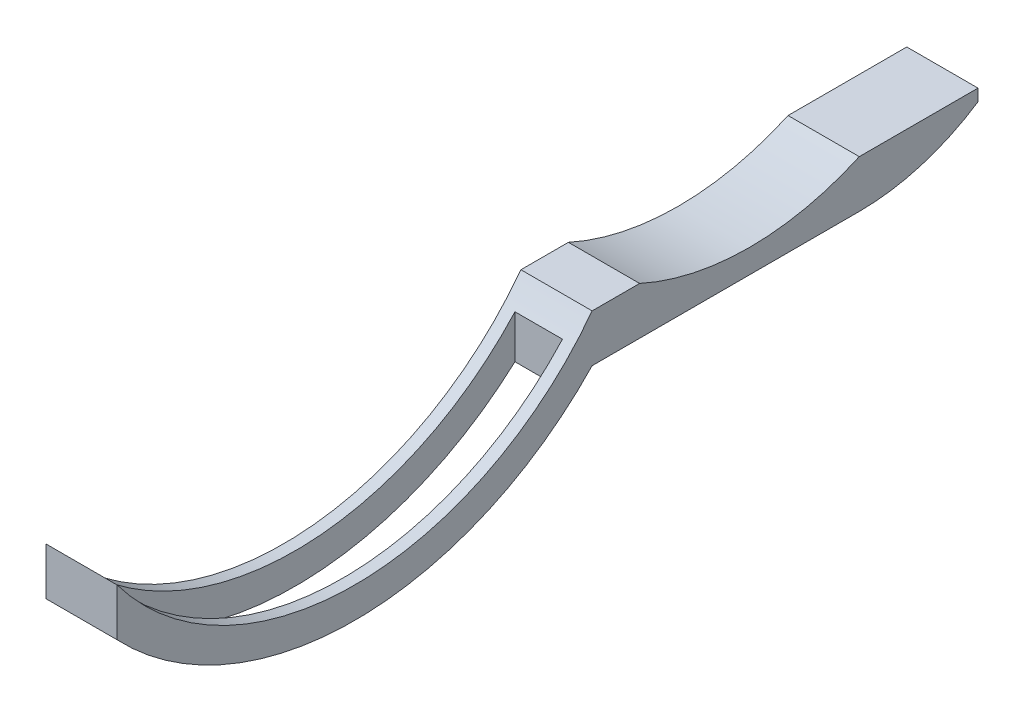
from build123d import *

# Parameters (mm, degrees)
BOSS_EXTRUDE1_DEPTH     = 12
SKETCH2_W               = 8
SKETCH2_H               = 75
CUT_EXTRUDE1_DEPTH      = 9
CUT_EXTRUDE1_DEPTH_BACK = 18.172456897


with BuildPart() as part:
    # Sketch1 → Boss-Extrude1 (new body)
    with BuildSketch(Plane(origin=(0, 0, 0), x_dir=(0, 0, -1), z_dir=(1, 0, 0))):
        with BuildLine():
            Line((0, 0), (0, 8))
            ThreePointArc((0, 8), (40, -12), (80, 8))
            Line((80, 8), (88, 8))
            ThreePointArc((88, 8), (106.5, 4), (125, 8))
            Line((125, 8), (145, 8))
            Line((145, 8), (145, 6))
            ThreePointArc((145, 6), (135.440306509, 1.532311637), (125, 0))
            Line((125, 0), (80, 0))
            ThreePointArc((80, 0), (40, -17.172456897), (0, 0))
        make_face()
    extrude(amount=BOSS_EXTRUDE1_DEPTH)

    # Sketch2 → Cut-Extrude1 (cut, two sides)
    with BuildSketch(Plane(origin=(0, 0, 0), x_dir=(1, 0, 0), z_dir=(0, 1, 0))) as cut_extrude1_sk:
        with Locations((6, 39.5)):
            Rectangle(SKETCH2_W, SKETCH2_H)
    extrude(amount=CUT_EXTRUDE1_DEPTH, mode=Mode.SUBTRACT)
    extrude(cut_extrude1_sk.sketch, amount=-CUT_EXTRUDE1_DEPTH_BACK, mode=Mode.SUBTRACT)


solid = part.part
